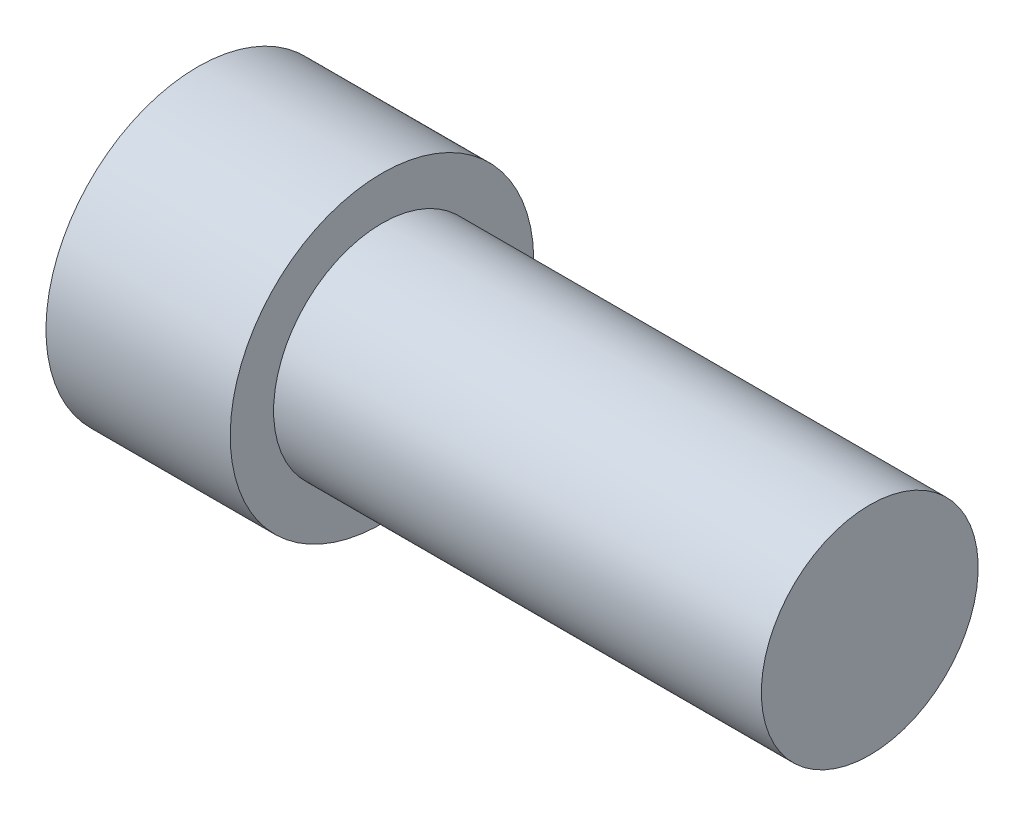
from build123d import *

# Parameters (mm, degrees)
CUT_EXTRUDE1_DEPTH = 10


with BuildPart() as part:
    # Sketch1 → Revolve1 (revolve)
    with BuildSketch(Plane.XY):
        Polygon((-31, 0.286378632), (-31, 14.286378632), (-14, 14.286378632), (-14, 10.286378632), (31, 10.286378632), (31, 0.286378632), align=None)
    revolve(axis=Axis((31, 0.286378632, 0), (-1, 0, 0)))

    # Sketch2 → Cut-Extrude1 (cut)
    with BuildSketch(Plane.ZY.offset(31)):
        Polygon((11.547005384, 0), (5.773502692, 10), (-5.773502692, 10), (-11.547005384, 0), (-5.773502692, -10), (5.773502692, -10), align=None)
    extrude(amount=-CUT_EXTRUDE1_DEPTH, mode=Mode.SUBTRACT)


solid = part.part
